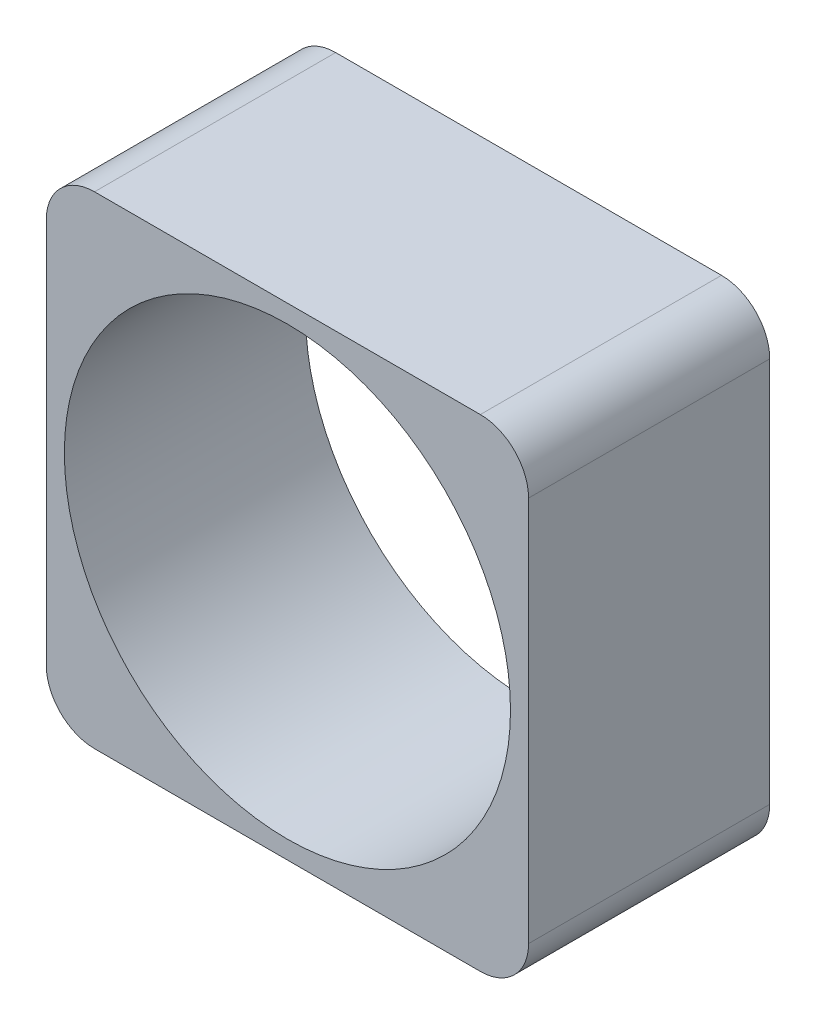
from build123d import *

# Parameters (mm, degrees)
ESTRUSIONE_ESTRUSIONE1_DEPTH = 20
SCHIZZO2_R                   = 18.5
TAGLIO_ESTRUSIONE1_DEPTH     = 20


with BuildPart() as part:
    # Schizzo1 → Estrusione-Estrusione1 (new body)
    with BuildSketch(Plane.XY):
        with BuildLine():
            Line((16, -20), (-16, -20))
            ThreePointArc((-16, -20), (-18.828427125, -18.828427125), (-20, -16))
            Line((-20, -16), (-20, 16))
            ThreePointArc((-20, 16), (-18.828427125, 18.828427125), (-16, 20))
            Line((-16, 20), (16, 20))
            ThreePointArc((16, 20), (18.828427125, 18.828427125), (20, 16))
            Line((20, 16), (20, -16))
            ThreePointArc((20, -16), (18.828427125, -18.828427125), (16, -20))
        make_face()
    extrude(amount=ESTRUSIONE_ESTRUSIONE1_DEPTH)

    # Schizzo2 → Taglio-Estrusione1 (cut)
    with BuildSketch(Plane.XY.offset(20)):
        Circle(SCHIZZO2_R)
    extrude(amount=-TAGLIO_ESTRUSIONE1_DEPTH, mode=Mode.SUBTRACT)


solid = part.part
